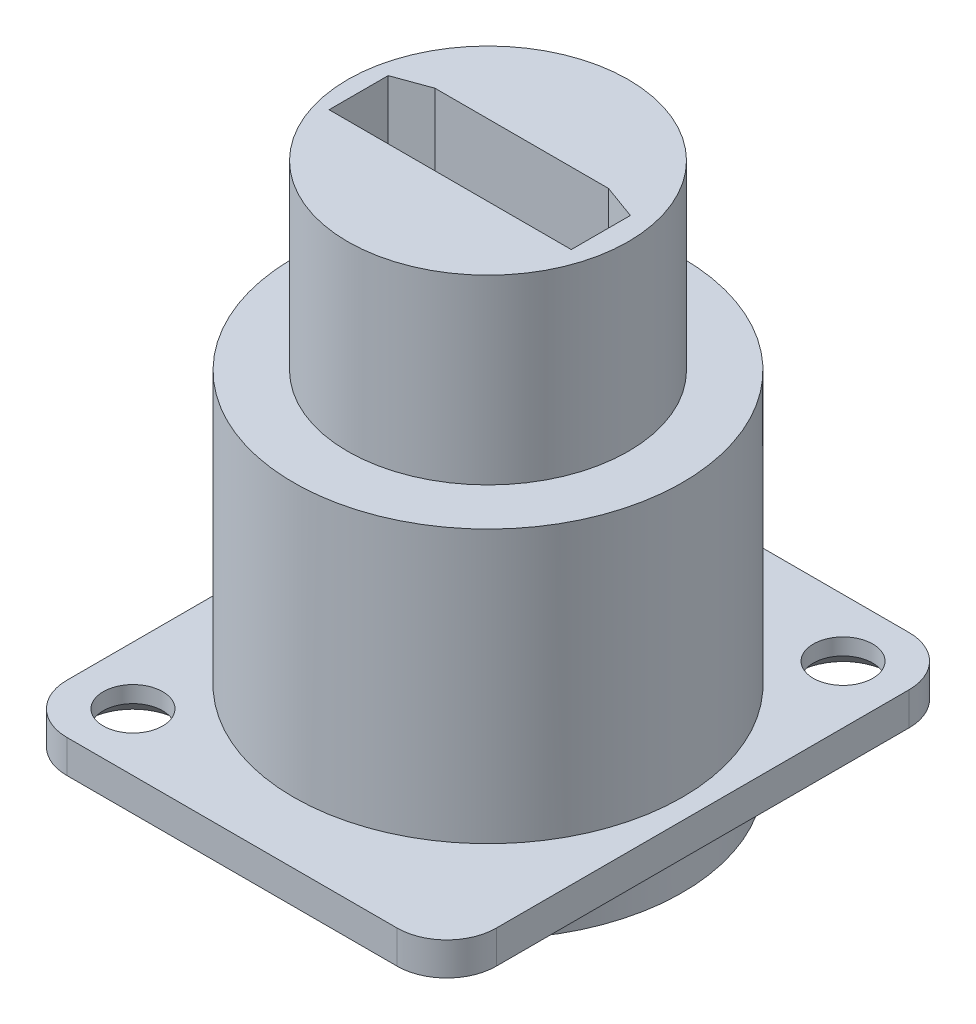
from build123d import *

# Parameters (mm, degrees)
SKETCH1_W           = 26
SKETCH1_H           = 31
EXTRUDE1_DEPTH      = 2
SKETCH2_R           = 11.775
EXTRUDE2_DEPTH      = 3
EXTRUDE2_DEPTH_BACK = 18.5
SKETCH3_R           = 8.5
EXTRUDE3_DEPTH      = 11
SKETCH4_R           = 10
SKETCH4_R_2         = 8.5
EXTRUDE4_DEPTH      = 15
EXTRUDE5_DEPTH      = 10
SKETCH9_R           = 1.8
EXTRUDE6_DEPTH      = 10
CHAMFER1_SIZE       = 1
FILLET1_R           = 3
EXTRUDE7_DEPTH      = 10


with BuildPart() as part:
    # Sketch1 → Extrude1 (new body)
    with BuildSketch(Plane(origin=(0, 0, 0), x_dir=(1, 0, 0), z_dir=(0, 1, 0))):
        with Locations((13, -15.5)):
            Rectangle(SKETCH1_W, SKETCH1_H)
    extrude(amount=EXTRUDE1_DEPTH)

    # Sketch2 → Extrude2 (add, two sides)
    with BuildSketch(Plane(origin=(0, 0, 0), x_dir=(-1, 0, 0), z_dir=(0, -1, 0))) as extrude2_sk:
        with Locations((-13, -15.5)):
            Circle(SKETCH2_R)
    extrude(amount=EXTRUDE2_DEPTH)
    extrude(extrude2_sk.sketch, amount=-EXTRUDE2_DEPTH_BACK)

    # Sketch3 → Extrude3 (add)
    with BuildSketch(Plane(origin=(0, 18.5, 0), x_dir=(1, 0, 0), z_dir=(0, 1, 0))):
        with Locations((13, -15.5)):
            Circle(SKETCH3_R)
    extrude(amount=EXTRUDE3_DEPTH)

    # Sketch4 → Extrude4 (cut)
    with BuildSketch(Plane(origin=(0, -3, 0), x_dir=(-1, 0, 0), z_dir=(0, -1, 0))):
        with Locations((-13, -15.5)):
            Circle(SKETCH4_R)
        with Locations((-13, -15.5)):
            Circle(SKETCH4_R_2, mode=Mode.SUBTRACT)
    extrude(amount=-EXTRUDE4_DEPTH, mode=Mode.SUBTRACT)

    # Sketch5 → Extrude5 (cut)
    with BuildSketch(Plane(origin=(0, -3, 0), x_dir=(-1, 0, 0), z_dir=(0, -1, 0))):
        Polygon((-5.519295113, -14.065487649), (-7.596667184, -13.309386049), (-18.109711193, -13.309386049), (-20.187083264, -14.065487649), (-20.187083264, -17.643859967), (-5.519295113, -17.643859967), align=None)
    extrude(amount=-EXTRUDE5_DEPTH, mode=Mode.SUBTRACT)

    # Sketch9 → Extrude6 (cut)
    with BuildSketch(Plane.XZ):
        with Locations((3.5, 27.5)):
            Circle(SKETCH9_R)
        with Locations((22.5, 3.5)):
            Circle(SKETCH9_R)
    extrude(amount=-EXTRUDE6_DEPTH, mode=Mode.SUBTRACT)

    # Chamfer1
    chamfer1_edges = [part.edges().sort_by_distance(p)[0] for p in [
        (1.7, 0, 27.5),
        (20.7, 0, 3.5),
    ]]
    chamfer(chamfer1_edges, length=CHAMFER1_SIZE)

    # Fillet1
    fillet1_edges = [part.edges().sort_by_distance(p)[0] for p in [
        (0, 1, 0),
        (26, 1, 0),
        (26, 1, 31),
        (0, 1, 31),
    ]]
    fillet(fillet1_edges, radius=FILLET1_R)

    # Sketch10 → Extrude7 (cut)
    with BuildSketch(Plane(origin=(0, 29.5, 0), x_dir=(1, 0, 0), z_dir=(0, 1, 0))):
        Polygon((5.519295113, -14.065487649), (5.519295113, -17.643859967), (20.187083264, -17.643859967), (20.187083264, -14.065487649), (18.109711193, -13.309386049), (7.596667184, -13.309386049), align=None)
    extrude(amount=-EXTRUDE7_DEPTH, mode=Mode.SUBTRACT)


solid = part.part
